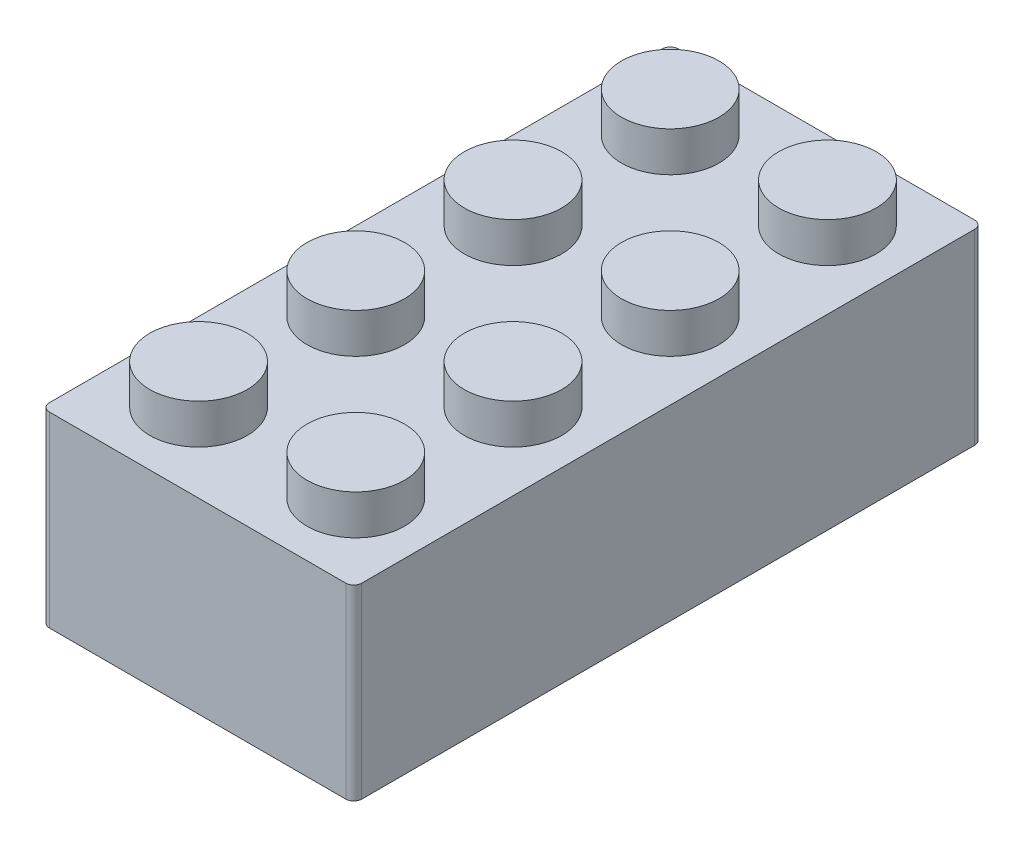
from build123d import *

# Parameters (mm, degrees)
SKETCH1_W           = 15.7
SKETCH1_H           = 31.6
BOSS_EXTRUDE1_DEPTH = 4.7
SKETCH2_R           = 2.45
BOSS_EXTRUDE2_DEPTH = 2
SKETCH3_W           = 12.9
SKETCH3_H           = 28.8
CUT_EXTRUDE1_DEPTH  = 4
SKETCH4_R           = 3.2
SKETCH4_R_2         = 2.4
BOSS_EXTRUDE3_DEPTH = 4
FILLET1_R           = 0.4


with BuildPart() as part:
    # Sketch1 → Boss-Extrude1 (new body, symmetric)
    with BuildSketch(Plane(origin=(0, 0, 0), x_dir=(1, 0, 0), z_dir=(0, 1, 0))):
        with Locations((7.85, 15.8)):
            Rectangle(SKETCH1_W, SKETCH1_H)
    extrude(amount=BOSS_EXTRUDE1_DEPTH, both=True)

    # Sketch2 → Boss-Extrude2 (add)
    with BuildSketch(Plane(origin=(0, 4.7, 0), x_dir=(1, 0, 0), z_dir=(0, 1, 0))):
        with Locations((3.95, 3.95)):
            Circle(SKETCH2_R)
        with Locations((11.85, 3.95)):
            Circle(SKETCH2_R)
        with Locations((11.85, 11.85)):
            Circle(SKETCH2_R)
        with Locations((3.95, 11.85)):
            Circle(SKETCH2_R)
        with Locations((3.95, 19.75)):
            Circle(SKETCH2_R)
        with Locations((11.85, 19.75)):
            Circle(SKETCH2_R)
        with Locations((3.95, 27.65)):
            Circle(SKETCH2_R)
        with Locations((11.85, 27.65)):
            Circle(SKETCH2_R)
    extrude(amount=BOSS_EXTRUDE2_DEPTH)

    # Sketch3 → Cut-Extrude1 (cut)
    with BuildSketch(Plane.XZ.offset(4.7)):
        with Locations((7.85, -15.8)):
            Rectangle(SKETCH3_W, SKETCH3_H)
    extrude(amount=-CUT_EXTRUDE1_DEPTH, mode=Mode.SUBTRACT)

    # Sketch4 → Boss-Extrude3 (add)
    with BuildSketch(Plane.XZ.offset(0.7)):
        with Locations((7.85, -7.9)):
            Circle(SKETCH4_R)
        with Locations((7.85, -7.9)):
            Circle(SKETCH4_R_2, mode=Mode.SUBTRACT)
        with Locations((7.85, -15.8)):
            Circle(SKETCH4_R)
        with Locations((7.85, -15.8)):
            Circle(SKETCH4_R_2, mode=Mode.SUBTRACT)
        with Locations((7.85, -23.7)):
            Circle(SKETCH4_R)
        with Locations((7.85, -23.7)):
            Circle(SKETCH4_R_2, mode=Mode.SUBTRACT)
    extrude(amount=BOSS_EXTRUDE3_DEPTH)

    # Fillet1
    fillet1_edges = [part.edges().sort_by_distance(p)[0] for p in [
        (0, 0, -31.6),
        (15.7, 0, -31.6),
        (15.7, 0, 0),
        (0, 0, 0),
    ]]
    fillet(fillet1_edges, radius=FILLET1_R)


solid = part.part
